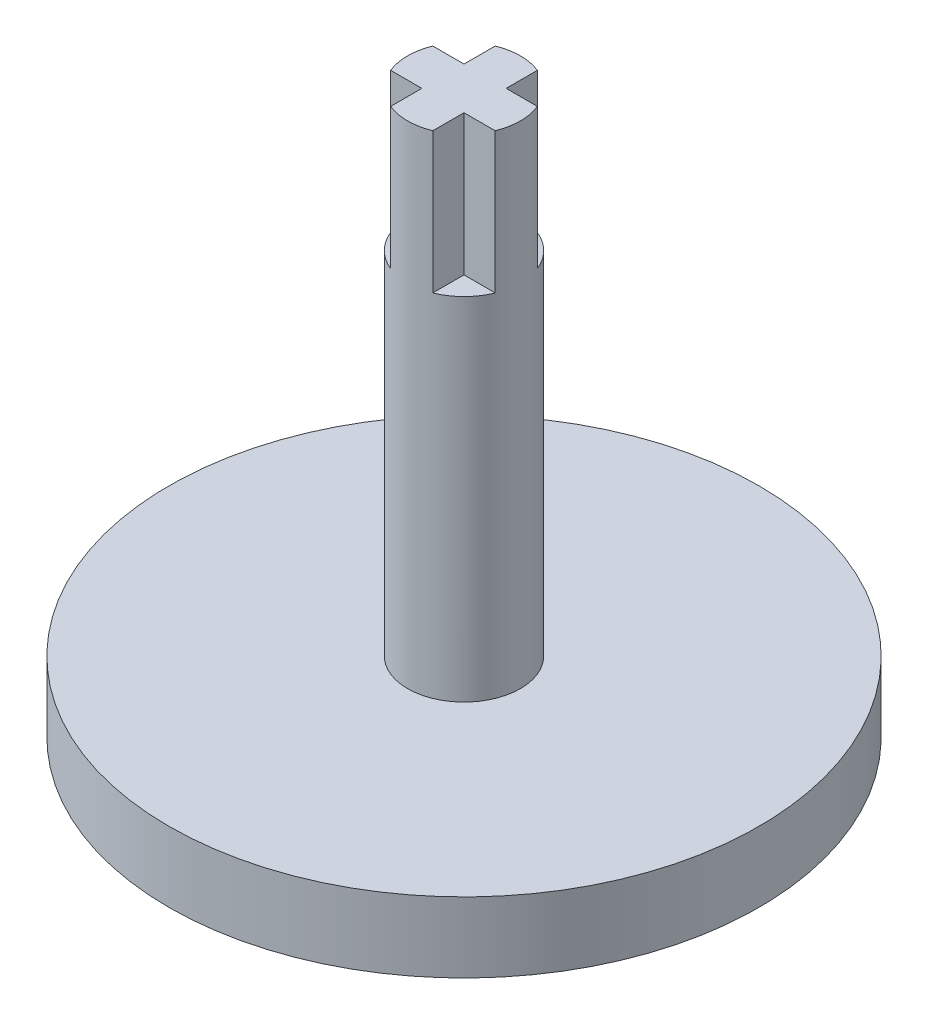
from build123d import *

# Parameters (mm, degrees)
SKETCH_1_R               = 21
EXTRUDE_1_DEPTH          = 5
SKETCH_3_R               = 6.05
CUT_EXTRUDE_2_DEPTH      = 3.5
SKETCH_4_R               = 4.015
EXTRUDE_2_DEPTH          = 25
SKETCH_12_R              = 5.15
CUT_EXTRUDE_6_DEPTH      = 3
PATTERN_CIRCULAR_1_COUNT = 8
SKETCH_13_W              = 3
SKETCH_13_H              = 3
EXTRUDE_3_DEPTH          = 10


with BuildPart() as part:
    # 스케치1 → 보스-돌출1 (new body)
    with BuildSketch(Plane(origin=(0, 0, 0), x_dir=(1, 0, 0), z_dir=(0, 1, 0))):
        Circle(SKETCH_1_R)
    extrude(amount=EXTRUDE_1_DEPTH)

    # 스케치3 → 컷-돌출2 (cut)
    with BuildSketch(Plane.XZ):
        Circle(SKETCH_3_R)
    extrude(amount=-CUT_EXTRUDE_2_DEPTH, mode=Mode.SUBTRACT)

    # 스케치4 → 보스-돌출2 (add)
    with BuildSketch(Plane(origin=(0, 5, 0), x_dir=(1, 0, 0), z_dir=(0, 1, 0))):
        Circle(SKETCH_4_R)
    extrude(amount=EXTRUDE_2_DEPTH)

    # 스케치12 → 컷-돌출6 (cut)
    with BuildSketch(Plane.XZ):
        with Locations((0, -14.5)):
            Circle(SKETCH_12_R)
    cut_extrude_6 = extrude(amount=-CUT_EXTRUDE_6_DEPTH, mode=Mode.SUBTRACT)

    # 원형 패턴1: 컷-돌출6 ×8 about axis
    pattern_circular_1_axis = Axis((0, 0, 0), (0, 1, 0))
    for i in range(1, PATTERN_CIRCULAR_1_COUNT):
        add(cut_extrude_6.rotate(pattern_circular_1_axis, i * 360 / PATTERN_CIRCULAR_1_COUNT), mode=Mode.SUBTRACT)

    # 스케치13 → 보스-돌출3 (add)
    with BuildSketch(Plane(origin=(0, 30, 0), x_dir=(1, 0, 0), z_dir=(0, 1, 0))):
        with BuildLine():
            ThreePointArc((1.5, 3.724275097), (0, 4.015), (-1.5, 3.724275097))
            Line((-1.5, 3.724275097), (-1.5, 1.5))
            Line((-1.5, 1.5), (1.5, 1.5))
            Line((1.5, 1.5), (1.5, 3.724275097))
        make_face()
        with BuildLine():
            Line((-1.5, -1.5), (-1.5, 1.5))
            Line((-1.5, 1.5), (-3.724275097, 1.5))
            ThreePointArc((-3.724275097, 1.5), (-4.015, 0), (-3.724275097, -1.5))
            Line((-3.724275097, -1.5), (-1.5, -1.5))
        make_face()
        Rectangle(SKETCH_13_W, SKETCH_13_H)
        with BuildLine():
            Line((1.5, -1.5), (-1.5, -1.5))
            Line((-1.5, -1.5), (-1.5, -3.724275097))
            ThreePointArc((-1.5, -3.724275097), (0, -4.015), (1.5, -3.724275097))
            Line((1.5, -3.724275097), (1.5, -1.5))
        make_face()
        with BuildLine():
            Line((3.724275097, 1.5), (1.5, 1.5))
            Line((1.5, 1.5), (1.5, -1.5))
            Line((1.5, -1.5), (3.724275097, -1.5))
            ThreePointArc((3.724275097, -1.5), (3.941648736, -0.763956964), (4.015, 0))
            ThreePointArc((4.015, 0), (3.941648736, 0.763956964), (3.724275097, 1.5))
        make_face()
    extrude(amount=EXTRUDE_3_DEPTH)


solid = part.part
